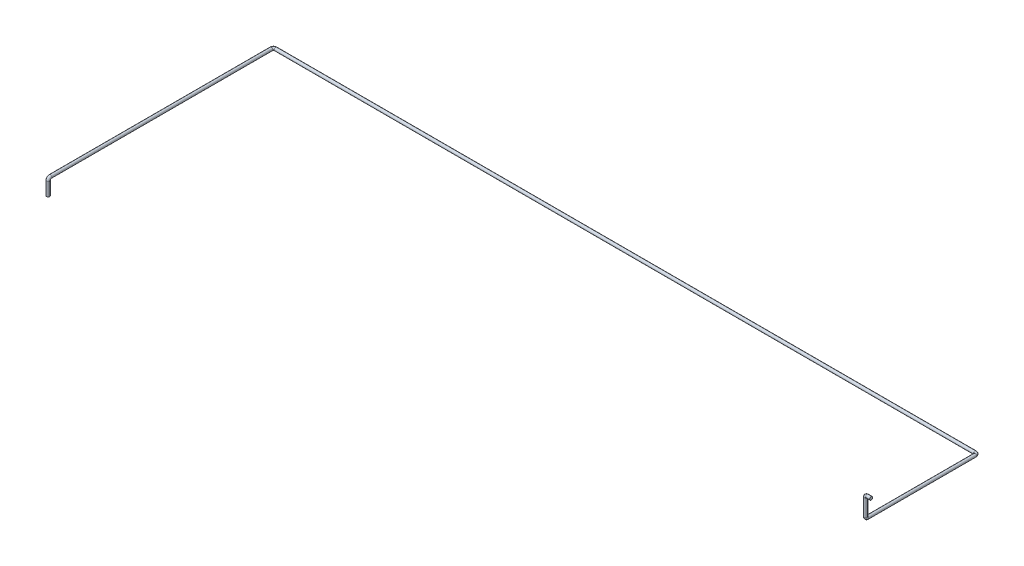
from build123d import *

# Parameters (mm, degrees)
CROQUIS1_R = 13.7


with BuildPart() as part:
    # Barrer1: sweep along a curve in space
    with BuildLine() as barrer1_path:
        Line((0, 0, 0), (-36, 0, 0))
        ThreePointArc((-36, 0, 0), (-45.899494937, -4.100505063, 0), (-50, -14, 0))
        Line((-50, -14, 0), (-50, -166, 0))
        ThreePointArc((-50, -166, 0), (-50, -175.899494937, -4.100505063), (-50, -180, -14))
        Line((-50, -180, -14), (-50, -180, -980))
        ThreePointArc((-50, -180, -980), (-55.857864376, -180, -994.142135624), (-70, -180, -1000))
        Line((-70, -180, -1000), (-6340, -180, -1000))
        ThreePointArc((-6340, -180, -1000), (-6354.142135624, -180, -994.142135624), (-6360, -180, -980))
        Line((-6360, -180, -980), (-6360, -180, 1000))
        ThreePointArc((-6360, -180, 1000), (-6360, -185.857864376, 1014.142135624), (-6360, -200, 1020))
        Line((-6360, -200, 1020), (-6360, -320, 1020))
    # Croquis1 → Barrer1 (sweep)
    with BuildSketch(Plane(origin=(0, 0, 0), x_dir=(0, 0, -1), z_dir=(1, 0, 0))):
        Circle(CROQUIS1_R)
    sweep(path=barrer1_path.line)


solid = part.part
